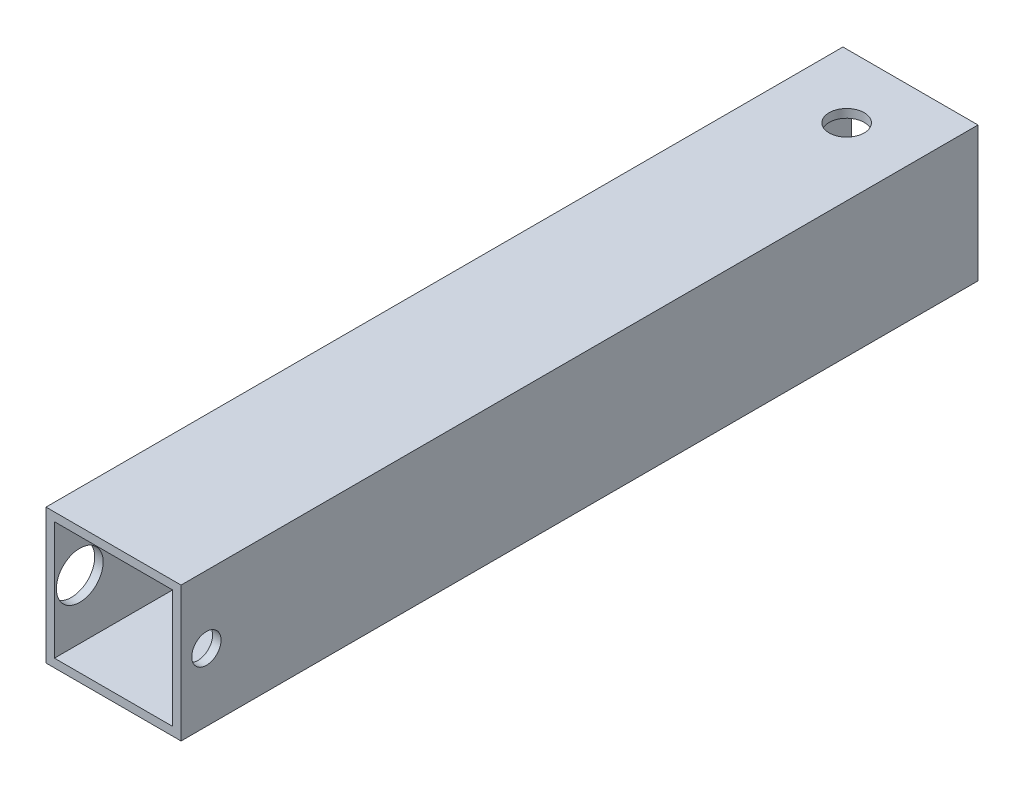
from build123d import *

# Parameters (mm, degrees)
SKETCH1_W                      = 25.4
SKETCH1_H                      = 25.4
BOSS_EXTRUDE1_DEPTH            = 74.93
SHELL1_T                       = -1.5875
CBORE_FOR_M5_SHCS1_D           = 5.5
CBORE_FOR_M5_SHCS1_CBORE_D     = 8.8
CBORE_FOR_M5_SHCS1_CBORE_DEPTH = 5
M6_CLEARANCE_HOLE1_D           = 6.6


with BuildPart() as part:
    # Sketch1 → Boss-Extrude1 (new body, symmetric)
    with BuildSketch(Plane.XY):
        Rectangle(SKETCH1_W, SKETCH1_H)
    extrude(amount=BOSS_EXTRUDE1_DEPTH, both=True)

    # Shell1
    shell1_openings = [part.faces().sort_by_distance(p)[0] for p in [
        (0, 0, 74.93),
        (0, 0, -74.93),
    ]]
    offset(amount=SHELL1_T, openings=shell1_openings, kind=Kind.INTERSECTION)

    # CBORE for M5 SHCS1 (through all)
    with Locations(Plane.ZY.offset(12.7)):
        with Locations((70.1675, 0)):
            CounterBoreHole(CBORE_FOR_M5_SHCS1_D / 2, CBORE_FOR_M5_SHCS1_CBORE_D / 2, CBORE_FOR_M5_SHCS1_CBORE_DEPTH)

    # M6 Clearance Hole1 (through all)
    with Locations(Plane(origin=(0, -12.7, 0), x_dir=(-1, 0, 0), z_dir=(0, -1, 0))):
        with Locations((0, 62.93)):
            Hole(M6_CLEARANCE_HOLE1_D / 2)


solid = part.part
